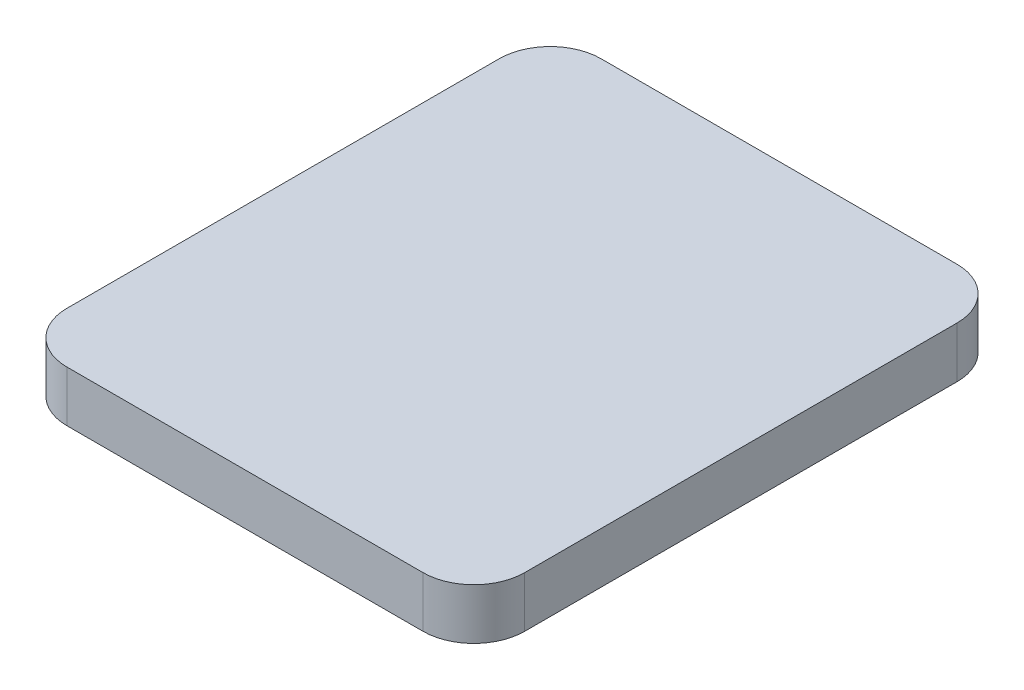
from build123d import *

# Parameters (mm, degrees)
SKETCH1_W           = 18
SKETCH1_H           = 21
BOSS_EXTRUDE1_DEPTH = 2
FILLET1_R           = 2


with BuildPart() as part:
    # Sketch1 → Boss-Extrude1 (new body)
    with BuildSketch(Plane(origin=(0, 0, 0), x_dir=(1, 0, 0), z_dir=(0, 1, 0))):
        Rectangle(SKETCH1_W, SKETCH1_H)
    extrude(amount=BOSS_EXTRUDE1_DEPTH)

    # Fillet1
    fillet1_edges = [part.edges().sort_by_distance(p)[0] for p in [
        (9, 1, 10.5),
        (-9, 1, 10.5),
        (-9, 1, -10.5),
        (9, 1, -10.5),
    ]]
    fillet(fillet1_edges, radius=FILLET1_R)


solid = part.part
